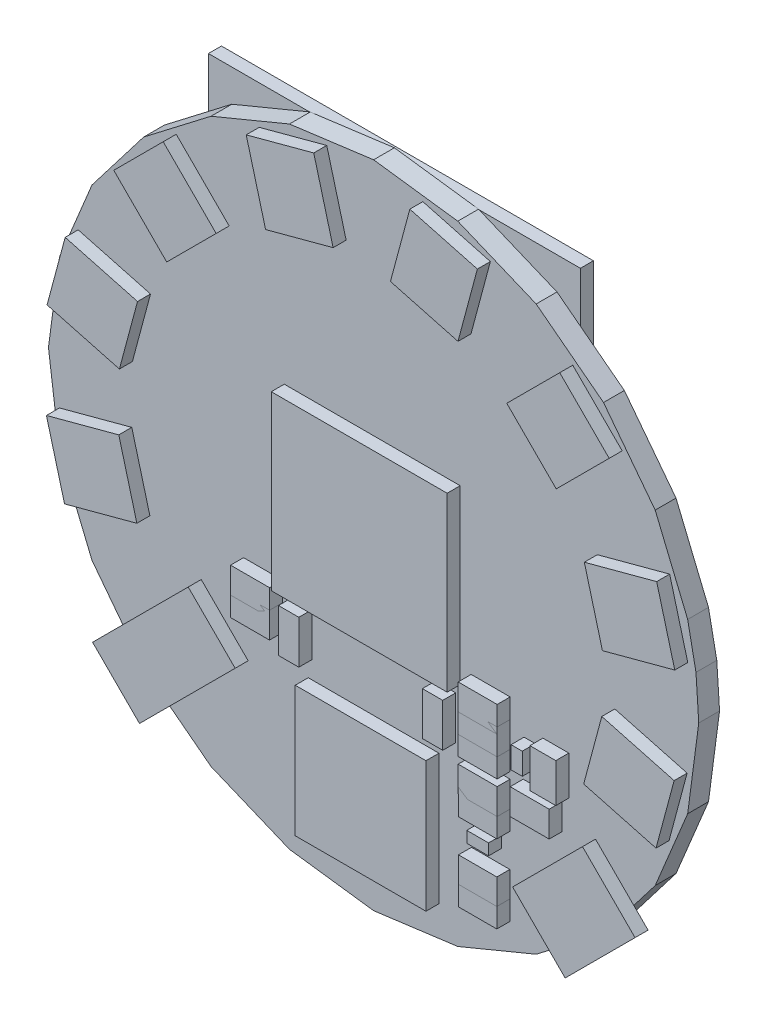
from build123d import *

# Parameters (mm, degrees)
BOARD_DEPTH                   = 1.6
WS2812B_1_DEPTH               = 1
WS2812B_2_DEPTH               = 1
WS2812B_3_DEPTH               = 1
WS2812B_4_DEPTH               = 1
WS2812B_5_DEPTH               = 1
WS2812B_6_DEPTH               = 1
WS2812B_7_DEPTH               = 1
WS2812B_8_DEPTH               = 1
ESQUISSE10_W                  = 28.6
ESQUISSE10_H                  = 20.254
F_3V_BAT_HOLDER_1_DEPTH       = 1
ESQUISSE11_W                  = 2.9968
ESQUISSE11_H                  = 1.9914
EXTRUDE_C0603_1_DEPTH         = 1
ESQUISSE12_W                  = 2.9968
ESQUISSE12_H                  = 1.9914
EXTRUDE_C0603_2_DEPTH         = 1
ESQUISSE13_W                  = 2.9968
ESQUISSE13_H                  = 1.9914
EXTRUDE_C0603_3_DEPTH         = 1
ESQUISSE14_W                  = 2.9968
ESQUISSE14_H                  = 1.9914
EXTRUDE_C0603_4_DEPTH         = 1
ESQUISSE15_W                  = 1.9914
ESQUISSE15_H                  = 2.9968
EXTRUDE_C0603_5_DEPTH         = 1
ESQUISSE16_W                  = 2.9968
ESQUISSE16_H                  = 1.9914
EXTRUDE_C0603_6_DEPTH         = 1
ESQUISSE17_W                  = 2.9968
ESQUISSE17_H                  = 1.9914
EXTRUDE_C0603_7_DEPTH         = 1
ESQUISSE18_W                  = 2.9968
ESQUISSE18_H                  = 1.9914
EXTRUDE_C0603_8_DEPTH         = 1
ESQUISSE19_W                  = 1.8423
ESQUISSE19_H                  = 1.4501
C0805POL_1_DEPTH              = 1
ESQUISSE20_W                  = 1.9914
ESQUISSE20_H                  = 3.9968
EXTRUDE_C0805_1_DEPTH         = 1
ESQUISSE21_W                  = 3.9968
ESQUISSE21_H                  = 1.9914
EXTRUDE_C0805_2_DEPTH         = 1
ESQUISSE22_W                  = 1.9914
ESQUISSE22_H                  = 2.9968
EXTRUDE_C0603_9_DEPTH         = 1
ESQUISSE23_W                  = 1.9914
ESQUISSE23_H                  = 2.9968
EXTRUDE_C0603_10_DEPTH        = 1
ESQUISSE24_W                  = 1.9914
ESQUISSE24_H                  = 2.9968
EXTRUDE_C0603_11_DEPTH        = 1
ESQUISSE25_W                  = 1.4501
ESQUISSE25_H                  = 1.8423
C0805POL_2_DEPTH              = 1
ESQUISSE26_W                  = 1.8423
ESQUISSE26_H                  = 1.4501
C0805POL_3_DEPTH              = 1
ESQUISSE27_W                  = 1.8423
ESQUISSE27_H                  = 1.4501
C0805POL_4_DEPTH              = 1
ESQUISSE28_W                  = 1.8423
ESQUISSE28_H                  = 1.4501
C0805POL_5_DEPTH              = 1
ESQUISSE29_W                  = 2.9968
ESQUISSE29_H                  = 1.9914
EXTRUDE_C0603_12_DEPTH        = 1
ESQUISSE30_W                  = 1.8423
ESQUISSE30_H                  = 1.4501
C0805POL_6_DEPTH              = 1
ESQUISSE31_W                  = 1.9914
ESQUISSE31_H                  = 3.9968
EXTRUDE_C0805_3_DEPTH         = 1
ESQUISSE32_W                  = 1.9914
ESQUISSE32_H                  = 3.9968
EXTRUDE_C0805_4_DEPTH         = 1
ESQUISSE33_W                  = 1.9914
ESQUISSE33_H                  = 3.9968
EXTRUDE_C0805_5_DEPTH         = 1
ESQUISSE34_W                  = 1.4501
ESQUISSE34_H                  = 1.8423
C0805POL_7_DEPTH              = 1
ESQUISSE35_W                  = 1.9914
ESQUISSE35_H                  = 2.9968
EXTRUDE_C0603_13_DEPTH        = 1
ESQUISSE36_W                  = 1.9914
ESQUISSE36_H                  = 2.9968
EXTRUDE_C0603_14_DEPTH        = 1
ESQUISSE37_W                  = 1.4501
ESQUISSE37_H                  = 1.8423
C0805POL_8_DEPTH              = 1
ESQUISSE38_W                  = 4.9968
ESQUISSE38_H                  = 1.9914
EXTRUDE_C1206_1_DEPTH         = 1
ESQUISSE39_W                  = 2.4
ESQUISSE39_H                  = 1.3635
SOD_323F_1_DEPTH              = 1
ESQUISSE40_W                  = 2.4
ESQUISSE40_H                  = 1.3635
SOD_323F_2_DEPTH              = 1
ESQUISSE41_W                  = 2.4
ESQUISSE41_H                  = 1.3635
SOD_323F_3_DEPTH              = 1
ESQUISSE42_W                  = 1.3635
ESQUISSE42_H                  = 2.4
SOD_323F_4_DEPTH              = 1
ESQUISSE43_W                  = 2.9968
ESQUISSE43_H                  = 1.9914
EXTRUDE_0603_1_DEPTH          = 1
ESQUISSE44_W                  = 3.3
ESQUISSE44_H                  = 3
SOT23_5_1_DEPTH               = 1
STEREOJACK2_5MM_1_DEPTH       = 1
ESQUISSE46_W                  = 7.2
ESQUISSE46_H                  = 7.2
LQFP32_08_1_DEPTH             = 1
ESQUISSE47_W                  = 1.6764
ESQUISSE47_H                  = 0.864
EXTRUDE_L0603_1_DEPTH         = 1
ESQUISSE48_W                  = 0.864
ESQUISSE48_H                  = 1.6764
EXTRUDE_L0603_2_DEPTH         = 1
ESQUISSE49_W                  = 1.6764
ESQUISSE49_H                  = 0.864
EXTRUDE_L0603_3_DEPTH         = 1
ESQUISSE50_W                  = 1.6764
ESQUISSE50_H                  = 0.864
EXTRUDE_L0603_4_DEPTH         = 1
ESQUISSE51_W                  = 0.864
ESQUISSE51_H                  = 1.6764
EXTRUDE_L0603_5_DEPTH         = 1
ESQUISSE52_R                  = 3
F6050AP_1_DEPTH               = 1
ESQUISSE53_W                  = 2.921
ESQUISSE53_H                  = 2.5908
SOT23_1_DEPTH                 = 1
ESQUISSE54_W                  = 2.946
ESQUISSE54_H                  = 1.966
EXTRUDE_R0603_1_DEPTH         = 1
ESQUISSE55_W                  = 2.946
ESQUISSE55_H                  = 1.966
EXTRUDE_R0603_2_DEPTH         = 1
ESQUISSE56_W                  = 2.946
ESQUISSE56_H                  = 1.966
EXTRUDE_R0603_3_DEPTH         = 1
ESQUISSE57_W                  = 1.966
ESQUISSE57_H                  = 2.946
EXTRUDE_R0603_4_DEPTH         = 1
ESQUISSE58_W                  = 1.966
ESQUISSE58_H                  = 2.946
EXTRUDE_R0603_5_DEPTH         = 1
ESQUISSE59_W                  = 2.946
ESQUISSE59_H                  = 1.966
EXTRUDE_R0603_6_DEPTH         = 1
ESQUISSE60_W                  = 2.946
ESQUISSE60_H                  = 1.966
EXTRUDE_R0603_7_DEPTH         = 1
ESQUISSE61_W                  = 1.966
ESQUISSE61_H                  = 2.946
EXTRUDE_R0603_8_DEPTH         = 1
ESQUISSE62_W                  = 1.966
ESQUISSE62_H                  = 2.946
EXTRUDE_R0603_9_DEPTH         = 1
ESQUISSE63_W                  = 1.966
ESQUISSE63_H                  = 2.946
EXTRUDE_R0603_10_DEPTH        = 1
ESQUISSE64_W                  = 1.966
ESQUISSE64_H                  = 2.946
EXTRUDE_R0603_11_DEPTH        = 1
ESQUISSE65_W                  = 1.966
ESQUISSE65_H                  = 2.946
EXTRUDE_R0603_12_DEPTH        = 1
ESQUISSE66_W                  = 1.966
ESQUISSE66_H                  = 2.946
EXTRUDE_R0603_13_DEPTH        = 1
ESQUISSE67_W                  = 2.946
ESQUISSE67_H                  = 1.966
EXTRUDE_R0603_14_DEPTH        = 1
ESQUISSE68_W                  = 1.966
ESQUISSE68_H                  = 2.946
EXTRUDE_R0603_15_DEPTH        = 1
ESQUISSE69_W                  = 2.667
ESQUISSE69_H                  = 4.0513
F_157SW_1_DEPTH               = 1
ESQUISSE70_W                  = 6.152916
ESQUISSE70_H                  = 5.0635
SMT_0540_S_R_1_DEPTH          = 1
ESQUISSE71_W                  = 13.52
ESQUISSE71_H                  = 13.25
ENCODER_LED_3_KIT_1_DEPTH     = 1
ESQUISSE72_W                  = 2.9202
ESQUISSE72_H                  = 3
SOT23_DBV_1_DEPTH             = 1
ESQUISSE73_W                  = 5.827
ESQUISSE73_H                  = 5.827
QFN_32_5MM_1_DEPTH            = 1
ESQUISSE74_W                  = 2.9736
ESQUISSE74_H                  = 3
SOT23_6_1_DEPTH               = 1
ESQUISSE75_W                  = 10.05
ESQUISSE75_H                  = 10.025
LQFP64_05_1_DEPTH             = 1
USB_MICRO_TG_1_DEPTH          = 1
ESQUISSE77_W                  = 1.5635
ESQUISSE77_H                  = 3.327
CRYSTAL_SMD_3_2X1_5MM_1_DEPTH = 1
ESQUISSE78_W                  = 1.5635
ESQUISSE78_H                  = 3.327
CRYSTAL_SMD_3_2X1_5MM_2_DEPTH = 1


with BuildPart() as part:
    # Esquisse1 → BOARD (new body)
    with BuildSketch(Plane.XY):
        Polygon((140.8, 53.6), (140.586122, 56.863155), (139.948146, 60.070476), (137.450635, 66.1), (133.47767, 71.27767), (128.3, 75.250635), (122.270476, 77.748146), (115.8, 78.6), (109.329524, 77.748146), (103.3, 75.250635), (98.122331, 71.27767), (94.149365, 66.1), (91.651854, 60.070476), (90.8, 53.6), (91.651854, 47.129524), (94.149365, 41.1), (98.12233, 35.922331), (103.3, 31.949365), (109.329524, 29.451854), (115.8, 28.6), (122.270476, 29.451854), (128.3, 31.949365), (133.477669, 35.92233), (137.450635, 41.1), (139.948146, 47.129524), align=None)
    extrude(amount=BOARD_DEPTH)


with BuildPart() as body_2:
    # Esquisse2 → WS2812B-1 (new body)
    with BuildSketch(Plane.XY.offset(1.6)):
        Polygon((91.644681403, 49.998124435), (97.20617418, 51.488321934), (98.597668707, 46.295193663), (93.036175929, 44.804996165), align=None)
    extrude(amount=WS2812B_1_DEPTH)


with BuildPart() as body_3:
    # Esquisse3 → WS2812B-2 (new body)
    with BuildSketch(Plane.XY.offset(1.6)):
        Polygon((93.085258373, 62.578182009), (98.64675115, 61.08798451), (97.255256624, 55.89485624), (91.693763847, 57.385053739), align=None)
    extrude(amount=WS2812B_2_DEPTH)


with BuildPart() as body_4:
    # Esquisse4 → WS2812B-3 (new body)
    with BuildSketch(Plane.XY.offset(1.6)):
        Polygon((100.622863412, 72.712866062), (104.694158691, 68.641570783), (100.892524947, 64.839937039), (96.821229668, 68.911232318), align=None)
    extrude(amount=WS2812B_3_DEPTH)


with BuildPart() as body_5:
    # Esquisse5 → WS2812B-4 (new body)
    with BuildSketch(Plane.XY.offset(1.6)):
        Polygon((112.198124435, 77.755318597), (113.688321934, 72.19382582), (108.495193663, 70.802331293), (107.004996165, 76.363824071), align=None)
    extrude(amount=WS2812B_4_DEPTH)


with BuildPart() as body_6:
    # Esquisse6 → WS2812B-5 (new body)
    with BuildSketch(Plane.XY.offset(1.6)):
        Polygon((124.778182009, 76.314741627), (123.28798451, 70.75324885), (118.09485624, 72.144743376), (119.585053739, 77.706236153), align=None)
    extrude(amount=WS2812B_5_DEPTH)


with BuildPart() as body_7:
    # Esquisse7 → WS2812B-6 (new body)
    with BuildSketch(Plane.XY.offset(1.6)):
        Polygon((134.912866062, 68.777136588), (130.841570783, 64.705841309), (127.039937039, 68.507475053), (131.111232318, 72.578770332), align=None)
    extrude(amount=WS2812B_6_DEPTH)


with BuildPart() as body_8:
    # Esquisse8 → WS2812B-7 (new body)
    with BuildSketch(Plane.XY.offset(1.6)):
        Polygon((139.955318597, 57.201875565), (134.39382582, 55.711678066), (133.002331293, 60.904806337), (138.563824071, 62.395003835), align=None)
    extrude(amount=WS2812B_7_DEPTH)


with BuildPart() as body_9:
    # Esquisse9 → WS2812B-8 (new body)
    with BuildSketch(Plane.XY.offset(1.6)):
        Polygon((138.514741627, 44.621817991), (132.95324885, 46.11201549), (134.344743376, 51.30514376), (139.906236153, 49.814946261), align=None)
    extrude(amount=WS2812B_8_DEPTH)


with BuildPart() as body_10:
    # Esquisse10 → 3V_BAT_HOLDER-1 (new body)
    with BuildSketch(Plane.XY):
        with Locations((115.8, 67.6)):
            Rectangle(ESQUISSE10_W, ESQUISSE10_H)
    extrude(amount=-F_3V_BAT_HOLDER_1_DEPTH)


with BuildPart() as body_11:
    # Esquisse11 → Extrude C0603-1 (new body)
    with BuildSketch(Plane.XY.offset(1.6)):
        with Locations((124.8, 41.6127)):
            Rectangle(ESQUISSE11_W, ESQUISSE11_H)
    extrude(amount=EXTRUDE_C0603_1_DEPTH)


with BuildPart() as body_12:
    # Esquisse12 → Extrude C0603-2 (new body)
    with BuildSketch(Plane.XY.offset(1.6)):
        with Locations((128.8, 42.1127)):
            Rectangle(ESQUISSE12_W, ESQUISSE12_H)
    extrude(amount=EXTRUDE_C0603_2_DEPTH)


with BuildPart() as body_13:
    # Esquisse13 → Extrude C0603-3 (new body)
    with BuildSketch(Plane.XY.offset(1.6)):
        with Locations((124.8, 44.1127)):
            Rectangle(ESQUISSE13_W, ESQUISSE13_H)
    extrude(amount=EXTRUDE_C0603_3_DEPTH)


with BuildPart() as body_14:
    # Esquisse14 → Extrude C0603-4 (new body)
    with BuildSketch(Plane.XY.offset(1.6)):
        with Locations((107.3, 44.6127)):
            Rectangle(ESQUISSE14_W, ESQUISSE14_H)
    extrude(amount=EXTRUDE_C0603_4_DEPTH)


with BuildPart() as body_15:
    # Esquisse15 → Extrude C0603-5 (new body)
    with BuildSketch(Plane.XY.offset(1.6)):
        with Locations((129.8127, 45.1)):
            Rectangle(ESQUISSE15_W, ESQUISSE15_H)
    extrude(amount=EXTRUDE_C0603_5_DEPTH)


with BuildPart() as body_16:
    # Esquisse16 → Extrude C0603-6 (new body)
    with BuildSketch(Plane.XY.offset(1.6)):
        with Locations((124.8, 45.5873)):
            Rectangle(ESQUISSE16_W, ESQUISSE16_H)
    extrude(amount=EXTRUDE_C0603_6_DEPTH)


with BuildPart() as body_17:
    # Esquisse17 → Extrude C0603-7 (new body)
    with BuildSketch(Plane.XY.offset(1.6)):
        with Locations((107.3, 46.1127)):
            Rectangle(ESQUISSE17_W, ESQUISSE17_H)
    extrude(amount=EXTRUDE_C0603_7_DEPTH)


with BuildPart() as body_18:
    # Esquisse18 → Extrude C0603-8 (new body)
    with BuildSketch(Plane.XY.offset(1.6)):
        with Locations((124.8, 47.0873)):
            Rectangle(ESQUISSE18_W, ESQUISSE18_H)
    extrude(amount=EXTRUDE_C0603_8_DEPTH)


with BuildPart() as body_19:
    # Esquisse19 → C0805POL-1 (new body)
    with BuildSketch(Plane.XY):
        with Locations((131.80675, 43.59885)):
            Rectangle(ESQUISSE19_W, ESQUISSE19_H)
    extrude(amount=-C0805POL_1_DEPTH)


with BuildPart() as body_20:
    # Esquisse20 → Extrude C0805-1 (new body)
    with BuildSketch(Plane.XY):
        with Locations((101.6873, 44)):
            Rectangle(ESQUISSE20_W, ESQUISSE20_H)
    extrude(amount=-EXTRUDE_C0805_1_DEPTH)


with BuildPart() as body_21:
    # Esquisse21 → Extrude C0805-2 (new body)
    with BuildSketch(Plane.XY):
        with Locations((97.6, 44.6127)):
            Rectangle(ESQUISSE21_W, ESQUISSE21_H)
    extrude(amount=-EXTRUDE_C0805_2_DEPTH)


with BuildPart() as body_22:
    # Esquisse22 → Extrude C0603-9 (new body)
    with BuildSketch(Plane.XY):
        with Locations((134.8127, 46.1)):
            Rectangle(ESQUISSE22_W, ESQUISSE22_H)
    extrude(amount=-EXTRUDE_C0603_9_DEPTH)


with BuildPart() as body_23:
    # Esquisse23 → Extrude C0603-10 (new body)
    with BuildSketch(Plane.XY):
        with Locations((110.8127, 47.1)):
            Rectangle(ESQUISSE23_W, ESQUISSE23_H)
    extrude(amount=-EXTRUDE_C0603_10_DEPTH)


with BuildPart() as body_24:
    # Esquisse24 → Extrude C0603-11 (new body)
    with BuildSketch(Plane.XY):
        with Locations((120.8127, 47.1)):
            Rectangle(ESQUISSE24_W, ESQUISSE24_H)
    extrude(amount=-EXTRUDE_C0603_11_DEPTH)


with BuildPart() as body_25:
    # Esquisse25 → C0805POL-2 (new body)
    with BuildSketch(Plane.XY):
        with Locations((124.29885, 47.09325)):
            Rectangle(ESQUISSE25_W, ESQUISSE25_H)
    extrude(amount=-C0805POL_2_DEPTH)


with BuildPart() as body_26:
    # Esquisse26 → C0805POL-3 (new body)
    with BuildSketch(Plane.XY):
        with Locations((97.59325, 48.60115)):
            Rectangle(ESQUISSE26_W, ESQUISSE26_H)
    extrude(amount=-C0805POL_3_DEPTH)


with BuildPart() as body_27:
    # Esquisse27 → C0805POL-4 (new body)
    with BuildSketch(Plane.XY):
        with Locations((127.79325, 48.60115)):
            Rectangle(ESQUISSE27_W, ESQUISSE27_H)
    extrude(amount=-C0805POL_4_DEPTH)


with BuildPart() as body_28:
    # Esquisse28 → C0805POL-5 (new body)
    with BuildSketch(Plane.XY):
        with Locations((127.79325, 51.10115)):
            Rectangle(ESQUISSE28_W, ESQUISSE28_H)
    extrude(amount=-C0805POL_5_DEPTH)


with BuildPart() as body_29:
    # Esquisse29 → Extrude C0603-12 (new body)
    with BuildSketch(Plane.XY):
        with Locations((135.8, 51.5873)):
            Rectangle(ESQUISSE29_W, ESQUISSE29_H)
    extrude(amount=-EXTRUDE_C0603_12_DEPTH)


with BuildPart() as body_30:
    # Esquisse30 → C0805POL-6 (new body)
    with BuildSketch(Plane.XY):
        with Locations((127.79325, 53.60115)):
            Rectangle(ESQUISSE30_W, ESQUISSE30_H)
    extrude(amount=-C0805POL_6_DEPTH)


with BuildPart() as body_31:
    # Esquisse31 → Extrude C0805-3 (new body)
    with BuildSketch(Plane.XY):
        with Locations((101.1873, 54.6)):
            Rectangle(ESQUISSE31_W, ESQUISSE31_H)
    extrude(amount=-EXTRUDE_C0805_3_DEPTH)


with BuildPart() as body_32:
    # Esquisse32 → Extrude C0805-4 (new body)
    with BuildSketch(Plane.XY):
        with Locations((103.2873, 54.6)):
            Rectangle(ESQUISSE32_W, ESQUISSE32_H)
    extrude(amount=-EXTRUDE_C0805_4_DEPTH)


with BuildPart() as body_33:
    # Esquisse33 → Extrude C0805-5 (new body)
    with BuildSketch(Plane.XY):
        with Locations((107.3127, 54.6)):
            Rectangle(ESQUISSE33_W, ESQUISSE33_H)
    extrude(amount=-EXTRUDE_C0805_5_DEPTH)


with BuildPart() as body_34:
    # Esquisse34 → C0805POL-7 (new body)
    with BuildSketch(Plane.XY):
        with Locations((134.80115, 54.60675)):
            Rectangle(ESQUISSE34_W, ESQUISSE34_H)
    extrude(amount=-C0805POL_7_DEPTH)


with BuildPart() as body_35:
    # Esquisse35 → Extrude C0603-13 (new body)
    with BuildSketch(Plane.XY):
        with Locations((118.2873, 57.6)):
            Rectangle(ESQUISSE35_W, ESQUISSE35_H)
    extrude(amount=-EXTRUDE_C0603_13_DEPTH)


with BuildPart() as body_36:
    # Esquisse36 → Extrude C0603-14 (new body)
    with BuildSketch(Plane.XY):
        with Locations((124.3127, 57.6)):
            Rectangle(ESQUISSE36_W, ESQUISSE36_H)
    extrude(amount=-EXTRUDE_C0603_14_DEPTH)


with BuildPart() as body_37:
    # Esquisse37 → C0805POL-8 (new body)
    with BuildSketch(Plane.XY):
        with Locations((128.29885, 61.59325)):
            Rectangle(ESQUISSE37_W, ESQUISSE37_H)
    extrude(amount=-C0805POL_8_DEPTH)


with BuildPart() as body_38:
    # Esquisse38 → Extrude C1206-1 (new body)
    with BuildSketch(Plane.XY):
        with Locations((131.8, 62.6127)):
            Rectangle(ESQUISSE38_W, ESQUISSE38_H)
    extrude(amount=-EXTRUDE_C1206_1_DEPTH)


with BuildPart() as body_39:
    # Esquisse39 → SOD-323F-1 (new body)
    with BuildSketch(Plane.XY):
        with Locations((127.8, 46.06825)):
            Rectangle(ESQUISSE39_W, ESQUISSE39_H)
    extrude(amount=-SOD_323F_1_DEPTH)


with BuildPart() as body_40:
    # Esquisse40 → SOD-323F-2 (new body)
    with BuildSketch(Plane.XY):
        with Locations((135.8, 49.63175)):
            Rectangle(ESQUISSE40_W, ESQUISSE40_H)
    extrude(amount=-SOD_323F_2_DEPTH)


with BuildPart() as body_41:
    # Esquisse41 → SOD-323F-3 (new body)
    with BuildSketch(Plane.XY):
        with Locations((131.8, 55.56825)):
            Rectangle(ESQUISSE41_W, ESQUISSE41_H)
    extrude(amount=-SOD_323F_3_DEPTH)


with BuildPart() as body_42:
    # Esquisse42 → SOD-323F-4 (new body)
    with BuildSketch(Plane.XY):
        with Locations((134.83175, 59.1)):
            Rectangle(ESQUISSE42_W, ESQUISSE42_H)
    extrude(amount=-SOD_323F_4_DEPTH)


with BuildPart() as body_43:
    # Esquisse43 → Extrude 0603-1 (new body)
    with BuildSketch(Plane.XY):
        with Locations((127.8, 43.6127)):
            Rectangle(ESQUISSE43_W, ESQUISSE43_H)
    extrude(amount=-EXTRUDE_0603_1_DEPTH)


with BuildPart() as body_44:
    # Esquisse44 → SOT23-5-1 (new body)
    with BuildSketch(Plane.XY):
        with Locations((131.8, 59.1)):
            Rectangle(ESQUISSE44_W, ESQUISSE44_H)
    extrude(amount=-SOT23_5_1_DEPTH)


with BuildPart() as body_45:
    # Esquisse45 → STEREOJACK2_5MM-1 (new body)
    with BuildSketch(Plane.XY.offset(1.6)):
        Polygon((95.192624045, 36.671842049), (102.546534569, 44.025752573), (106.153910524, 40.418376618), (98.8, 33.064466094), align=None)
    extrude(amount=STEREOJACK2_5MM_1_DEPTH)


with BuildPart() as body_46:
    # Esquisse46 → LQFP32-08-1 (new body)
    with BuildSketch(Plane.XY):
        with Locations((115.8, 36.6)):
            Rectangle(ESQUISSE46_W, ESQUISSE46_H)
    extrude(amount=-LQFP32_08_1_DEPTH)


with BuildPart() as body_47:
    # Esquisse47 → Extrude L0603-1 (new body)
    with BuildSketch(Plane.XY.offset(1.6)):
        with Locations((124.8, 38.0998)):
            Rectangle(ESQUISSE47_W, ESQUISSE47_H)
    extrude(amount=EXTRUDE_L0603_1_DEPTH)


with BuildPart() as body_48:
    # Esquisse48 → Extrude L0603-2 (new body)
    with BuildSketch(Plane.XY.offset(1.6)):
        with Locations((127.8002, 45.1)):
            Rectangle(ESQUISSE48_W, ESQUISSE48_H)
    extrude(amount=EXTRUDE_L0603_2_DEPTH)


with BuildPart() as body_49:
    # Esquisse49 → Extrude L0603-3 (new body)
    with BuildSketch(Plane.XY):
        with Locations((97.6, 46.5998)):
            Rectangle(ESQUISSE49_W, ESQUISSE49_H)
    extrude(amount=-EXTRUDE_L0603_3_DEPTH)


with BuildPart() as body_50:
    # Esquisse50 → Extrude L0603-4 (new body)
    with BuildSketch(Plane.XY):
        with Locations((97.6, 50.5998)):
            Rectangle(ESQUISSE50_W, ESQUISSE50_H)
    extrude(amount=-EXTRUDE_L0603_4_DEPTH)


with BuildPart() as body_51:
    # Esquisse51 → Extrude L0603-5 (new body)
    with BuildSketch(Plane.XY):
        with Locations((113.3002, 57.6)):
            Rectangle(ESQUISSE51_W, ESQUISSE51_H)
    extrude(amount=-EXTRUDE_L0603_5_DEPTH)


with BuildPart() as body_52:
    # Esquisse52 → F6050AP-1 (new body)
    with BuildSketch(Plane.XY):
        with Locations((115.8, 53.6)):
            Circle(ESQUISSE52_R)
    extrude(amount=-F6050AP_1_DEPTH)


with BuildPart() as body_53:
    # Esquisse53 → SOT23-1 (new body)
    with BuildSketch(Plane.XY):
        with Locations((101.2619, 61.6)):
            Rectangle(ESQUISSE53_W, ESQUISSE53_H)
    extrude(amount=-SOT23_1_DEPTH)


with BuildPart() as body_54:
    # Esquisse54 → Extrude R0603-1 (new body)
    with BuildSketch(Plane.XY.offset(1.6)):
        with Locations((124.8, 34.1)):
            Rectangle(ESQUISSE54_W, ESQUISSE54_H)
    extrude(amount=EXTRUDE_R0603_1_DEPTH)


with BuildPart() as body_55:
    # Esquisse55 → Extrude R0603-2 (new body)
    with BuildSketch(Plane.XY.offset(1.6)):
        with Locations((124.8, 35.6)):
            Rectangle(ESQUISSE55_W, ESQUISSE55_H)
    extrude(amount=EXTRUDE_R0603_2_DEPTH)


with BuildPart() as body_56:
    # Esquisse56 → Extrude R0603-3 (new body)
    with BuildSketch(Plane.XY.offset(1.6)):
        with Locations((124.8, 40.1)):
            Rectangle(ESQUISSE56_W, ESQUISSE56_H)
    extrude(amount=EXTRUDE_R0603_3_DEPTH)


with BuildPart() as body_57:
    # Esquisse57 → Extrude R0603-4 (new body)
    with BuildSketch(Plane.XY):
        with Locations((103.4, 35.4)):
            Rectangle(ESQUISSE57_W, ESQUISSE57_H)
    extrude(amount=-EXTRUDE_R0603_4_DEPTH)


with BuildPart() as body_58:
    # Esquisse58 → Extrude R0603-5 (new body)
    with BuildSketch(Plane.XY):
        with Locations((105.2, 35.4)):
            Rectangle(ESQUISSE58_W, ESQUISSE58_H)
    extrude(amount=-EXTRUDE_R0603_5_DEPTH)


with BuildPart() as body_59:
    # Esquisse59 → Extrude R0603-6 (new body)
    with BuildSketch(Plane.XY):
        with Locations((113.8, 48.1)):
            Rectangle(ESQUISSE59_W, ESQUISSE59_H)
    extrude(amount=-EXTRUDE_R0603_6_DEPTH)


with BuildPart() as body_60:
    # Esquisse60 → Extrude R0603-7 (new body)
    with BuildSketch(Plane.XY):
        with Locations((117.8, 48.1)):
            Rectangle(ESQUISSE60_W, ESQUISSE60_H)
    extrude(amount=-EXTRUDE_R0603_7_DEPTH)


with BuildPart() as body_61:
    # Esquisse61 → Extrude R0603-8 (new body)
    with BuildSketch(Plane.XY):
        with Locations((105.3, 54.6)):
            Rectangle(ESQUISSE61_W, ESQUISSE61_H)
    extrude(amount=-EXTRUDE_R0603_8_DEPTH)


with BuildPart() as body_62:
    # Esquisse62 → Extrude R0603-9 (new body)
    with BuildSketch(Plane.XY):
        with Locations((136.8, 54.6)):
            Rectangle(ESQUISSE62_W, ESQUISSE62_H)
    extrude(amount=-EXTRUDE_R0603_9_DEPTH)


with BuildPart() as body_63:
    # Esquisse63 → Extrude R0603-10 (new body)
    with BuildSketch(Plane.XY):
        with Locations((120.3, 57.6)):
            Rectangle(ESQUISSE63_W, ESQUISSE63_H)
    extrude(amount=-EXTRUDE_R0603_10_DEPTH)


with BuildPart() as body_64:
    # Esquisse64 → Extrude R0603-11 (new body)
    with BuildSketch(Plane.XY):
        with Locations((122.3, 57.6)):
            Rectangle(ESQUISSE64_W, ESQUISSE64_H)
    extrude(amount=-EXTRUDE_R0603_11_DEPTH)


with BuildPart() as body_65:
    # Esquisse65 → Extrude R0603-12 (new body)
    with BuildSketch(Plane.XY):
        with Locations((126.3, 57.6)):
            Rectangle(ESQUISSE65_W, ESQUISSE65_H)
    extrude(amount=-EXTRUDE_R0603_12_DEPTH)


with BuildPart() as body_66:
    # Esquisse66 → Extrude R0603-13 (new body)
    with BuildSketch(Plane.XY):
        with Locations((128.3, 57.6)):
            Rectangle(ESQUISSE66_W, ESQUISSE66_H)
    extrude(amount=-EXTRUDE_R0603_13_DEPTH)


with BuildPart() as body_67:
    # Esquisse67 → Extrude R0603-14 (new body)
    with BuildSketch(Plane.XY):
        with Locations((101.3, 58.1)):
            Rectangle(ESQUISSE67_W, ESQUISSE67_H)
    extrude(amount=-EXTRUDE_R0603_14_DEPTH)


with BuildPart() as body_68:
    # Esquisse68 → Extrude R0603-15 (new body)
    with BuildSketch(Plane.XY):
        with Locations((136.8, 59.1)):
            Rectangle(ESQUISSE68_W, ESQUISSE68_H)
    extrude(amount=-EXTRUDE_R0603_15_DEPTH)


with BuildPart() as body_69:
    # Esquisse69 → 157SW-1 (new body)
    with BuildSketch(Plane.XY):
        with Locations((124.3, 33.63785)):
            Rectangle(ESQUISSE69_W, ESQUISSE69_H)
    extrude(amount=-F_157SW_1_DEPTH)


with BuildPart() as body_70:
    # Esquisse70 → SMT-0540-S-R-1 (new body)
    with BuildSketch(Plane.XY):
        with Locations((95.787042, 60.63175)):
            Rectangle(ESQUISSE70_W, ESQUISSE70_H)
    extrude(amount=-SMT_0540_S_R_1_DEPTH)


with BuildPart() as body_71:
    # Esquisse71 → ENCODER_LED_3_KIT-1 (new body)
    with BuildSketch(Plane.XY.offset(1.6)):
        with Locations((115.693061, 53.6)):
            Rectangle(ESQUISSE71_W, ESQUISSE71_H)
    extrude(amount=ENCODER_LED_3_KIT_1_DEPTH)


with BuildPart() as body_72:
    # Esquisse72 → SOT23-DBV-1 (new body)
    with BuildSketch(Plane.XY):
        with Locations((131.8381, 47.1)):
            Rectangle(ESQUISSE72_W, ESQUISSE72_H)
    extrude(amount=-SOT23_DBV_1_DEPTH)


with BuildPart() as body_73:
    # Esquisse73 → QFN-32-5MM-1 (new body)
    with BuildSketch(Plane.XY):
        with Locations((103.5865, 48.8865)):
            Rectangle(ESQUISSE73_W, ESQUISSE73_H)
    extrude(amount=-QFN_32_5MM_1_DEPTH)


with BuildPart() as body_74:
    # Esquisse74 → SOT23-6-1 (new body)
    with BuildSketch(Plane.XY):
        with Locations((131.8368, 52.1)):
            Rectangle(ESQUISSE74_W, ESQUISSE74_H)
    extrude(amount=-SOT23_6_1_DEPTH)


with BuildPart() as body_75:
    # Esquisse75 → LQFP64-05-1 (new body)
    with BuildSketch(Plane.XY.offset(1.6)):
        with Locations((115.8, 36.5875)):
            Rectangle(ESQUISSE75_W, ESQUISSE75_H)
    extrude(amount=LQFP64_05_1_DEPTH)


with BuildPart() as body_76:
    # Esquisse76 → USB_MICRO_TG-1 (new body)
    with BuildSketch(Plane.XY.offset(1.6)):
        Polygon((131.528375691, 32.482056422), (127.487987343, 36.522444771), (132.86199888, 41.896456308), (136.902387228, 37.856067959), align=None)
    extrude(amount=USB_MICRO_TG_1_DEPTH)


with BuildPart() as body_77:
    # Esquisse77 → CRYSTAL-SMD-3_2X1_5MM-1 (new body)
    with BuildSketch(Plane.XY.offset(1.6)):
        with Locations((110.26825, 44.6)):
            Rectangle(ESQUISSE77_W, ESQUISSE77_H)
    extrude(amount=CRYSTAL_SMD_3_2X1_5MM_1_DEPTH)


with BuildPart() as body_78:
    # Esquisse78 → CRYSTAL-SMD-3_2X1_5MM-2 (new body)
    with BuildSketch(Plane.XY.offset(1.6)):
        with Locations((121.33175, 44.6)):
            Rectangle(ESQUISSE78_W, ESQUISSE78_H)
    extrude(amount=CRYSTAL_SMD_3_2X1_5MM_2_DEPTH)


solid = Compound([part.part, body_2.part, body_3.part, body_4.part, body_5.part, body_6.part, body_7.part, body_8.part, body_9.part, body_10.part, body_11.part, body_12.part, body_13.part, body_14.part, body_15.part, body_16.part, body_17.part, body_18.part, body_19.part, body_20.part, body_21.part, body_22.part, body_23.part, body_24.part, body_25.part, body_26.part, body_27.part, body_28.part, body_29.part, body_30.part, body_31.part, body_32.part, body_33.part, body_34.part, body_35.part, body_36.part, body_37.part, body_38.part, body_39.part, body_40.part, body_41.part, body_42.part, body_43.part, body_44.part, body_45.part, body_46.part, body_47.part, body_48.part, body_49.part, body_50.part, body_51.part, body_52.part, body_53.part, body_54.part, body_55.part, body_56.part, body_57.part, body_58.part, body_59.part, body_60.part, body_61.part, body_62.part, body_63.part, body_64.part, body_65.part, body_66.part, body_67.part, body_68.part, body_69.part, body_70.part, body_71.part, body_72.part, body_73.part, body_74.part, body_75.part, body_76.part, body_77.part, body_78.part])
